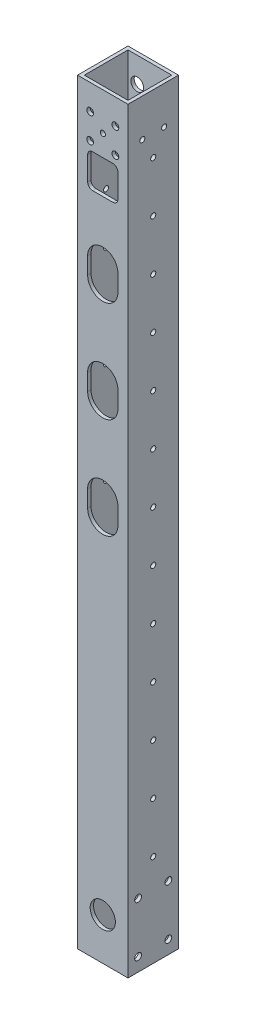
from build123d import *

# Parameters (mm, degrees)
SKETCH_2_W               = 30
SKETCH_2_H               = 30
EXTRUDE_1_DEPTH          = 225
SKETCH_4_W               = 26
SKETCH_4_H               = 26
CUT_EXTRUDE_1_DEPTH      = 226
CUT_EXTRUDE_1_DEPTH_BACK = 226
SKETCH_5_R               = 2.025
CUT_EXTRUDE_2_DEPTH      = 1
CUT_EXTRUDE_2_DEPTH_BACK = 31
SKETCH_7_R               = 1.525
CUT_EXTRUDE_3_DEPTH      = 1
CUT_EXTRUDE_3_DEPTH_BACK = 31
SKETCH_8_R               = 1.525
CUT_EXTRUDE_4_DEPTH      = 31
PATTERN_LINEAR_1_COUNT   = 13
PATTERN_LINEAR_1_PITCH   = 30
SKETCH_9_R               = 3.8
CUT_EXTRUDE_5_DEPTH      = 5
CUT_EXTRUDE_6_DEPTH      = 5
PATTERN_LINEAR_2_COUNT   = 7
PATTERN_LINEAR_2_PITCH   = 57
SKETCH_11_R              = 2.025
CUT_EXTRUDE_7_DEPTH      = 1
CUT_EXTRUDE_7_DEPTH_BACK = 31
CUT_EXTRUDE_8_DEPTH      = 10
SKETCH_14_R              = 1.525
CUT_EXTRUDE_9_DEPTH      = 1
CUT_EXTRUDE_9_DEPTH_BACK = 31
SKETCH_15_R              = 7.5
CUT_EXTRUDE_10_DEPTH     = 2


with BuildPart() as part:
    # 草图2 → 凸台-拉伸1 (new body, symmetric)
    with BuildSketch(Plane(origin=(0, 0, 0), x_dir=(1, 0, 0), z_dir=(0, 1, 0))):
        Rectangle(SKETCH_2_W, SKETCH_2_H)
    extrude(amount=EXTRUDE_1_DEPTH, both=True)

    # 草图4 → 切除-拉伸1 (cut, two sides)
    with BuildSketch(Plane(origin=(0, 0, 0), x_dir=(1, 0, 0), z_dir=(0, 1, 0))) as cut_extrude_1_sk:
        Rectangle(SKETCH_4_W, SKETCH_4_H)
    extrude(amount=CUT_EXTRUDE_1_DEPTH, mode=Mode.SUBTRACT)
    extrude(cut_extrude_1_sk.sketch, amount=-CUT_EXTRUDE_1_DEPTH_BACK, mode=Mode.SUBTRACT)

    # 草图5 → 切除-拉伸2 (cut, two sides)
    with BuildSketch(Plane(origin=(0, 0, -15), x_dir=(-1, 0, 0), z_dir=(0, 0, -1))) as cut_extrude_2_sk:
        with Locations((-7.5, 210)):
            Circle(SKETCH_5_R)
        with Locations((7.5, 210)):
            Circle(SKETCH_5_R)
        with Locations((-7.5, 195)):
            Circle(SKETCH_5_R)
        with Locations((7.5, 195)):
            Circle(SKETCH_5_R)
    extrude(amount=CUT_EXTRUDE_2_DEPTH, mode=Mode.SUBTRACT)
    extrude(cut_extrude_2_sk.sketch, amount=-CUT_EXTRUDE_2_DEPTH_BACK, mode=Mode.SUBTRACT)

    # 草图7 → 切除-拉伸3 (cut, two sides)
    with BuildSketch(Plane(origin=(15, 0, 0), x_dir=(0, 0, -1), z_dir=(1, 0, 0))) as cut_extrude_3_sk:
        with Locations((-6.5, 202.499999999)):
            Circle(SKETCH_7_R)
        with Locations((6.5, 202.499999999)):
            Circle(SKETCH_7_R)
    extrude(amount=CUT_EXTRUDE_3_DEPTH, mode=Mode.SUBTRACT)
    extrude(cut_extrude_3_sk.sketch, amount=-CUT_EXTRUDE_3_DEPTH_BACK, mode=Mode.SUBTRACT)

    # 草图8 → 切除-拉伸4 (cut, through all)
    with BuildSketch(Plane.ZY.offset(15)):
        with Locations((0, -170.000000001)):
            Circle(SKETCH_8_R)
    cut_extrude_4 = extrude(amount=-CUT_EXTRUDE_4_DEPTH, mode=Mode.SUBTRACT)

    # 阵列(线性)1: 切除-拉伸4 ×13
    with Locations(*[(0, i * PATTERN_LINEAR_1_PITCH, 0) for i in range(1, PATTERN_LINEAR_1_COUNT)]):
        add(cut_extrude_4, mode=Mode.SUBTRACT)

    # 草图9 → 切除-拉伸5 (cut)
    with BuildSketch(Plane(origin=(0, 0, -15), x_dir=(-1, 0, 0), z_dir=(0, 0, -1))):
        with Locations((-7.5, 210)):
            Circle(SKETCH_9_R)
        with Locations((7.5, 210)):
            Circle(SKETCH_9_R)
        with Locations((7.5, 195)):
            Circle(SKETCH_9_R)
        with Locations((-7.5, 195)):
            Circle(SKETCH_9_R)
    extrude(amount=-CUT_EXTRUDE_5_DEPTH, mode=Mode.SUBTRACT)

    # 草图10 → 切除-拉伸6 (cut)
    with BuildSketch(Plane(origin=(0, 0, -15), x_dir=(-1, 0, 0), z_dir=(0, 0, -1))):
        with BuildLine():
            Line((-9, -196.5), (-9, -165.5))
            ThreePointArc((-9, -165.5), (0, -156.5), (9, -165.5))
            Line((9, -165.5), (9, -196.5))
            ThreePointArc((9, -196.5), (0, -205.5), (-9, -196.5))
        make_face()
    cut_extrude_6 = extrude(amount=-CUT_EXTRUDE_6_DEPTH, mode=Mode.SUBTRACT)

    # 阵列(线性)2: 切除-拉伸6 ×7
    with Locations(*[(0, i * PATTERN_LINEAR_2_PITCH, 0) for i in range(1, PATTERN_LINEAR_2_COUNT)]):
        add(cut_extrude_6, mode=Mode.SUBTRACT)

    # 草图11 → 切除-拉伸7 (cut, two sides)
    with BuildSketch(Plane.ZY.offset(15)) as cut_extrude_7_sk:
        with Locations((-9, -187)):
            Circle(SKETCH_11_R)
        with Locations((9, -187)):
            Circle(SKETCH_11_R)
        with Locations((-9, -217)):
            Circle(SKETCH_11_R)
        with Locations((9, -217)):
            Circle(SKETCH_11_R)
    extrude(amount=CUT_EXTRUDE_7_DEPTH, mode=Mode.SUBTRACT)
    extrude(cut_extrude_7_sk.sketch, amount=-CUT_EXTRUDE_7_DEPTH_BACK, mode=Mode.SUBTRACT)

    # 草图13 → 切除-拉伸8 (cut)
    with BuildSketch(Plane.XY.offset(15)):
        with BuildLine():
            Line((-6, 190), (6, 190))
            ThreePointArc((6, 190), (8.121320344, 189.121320344), (9, 187))
            Line((9, 187), (9, 173))
            ThreePointArc((9, 173), (8.121320344, 170.878679656), (6, 170))
            Line((6, 170), (-6, 170))
            ThreePointArc((-6, 170), (-8.121320344, 170.878679656), (-9, 173))
            Line((-9, 173), (-9, 187))
            ThreePointArc((-9, 187), (-8.121320344, 189.121320344), (-6, 190))
        make_face()
        with BuildLine():
            Line((9, 135), (9, 125))
            ThreePointArc((9, 125), (0, 116), (-9, 125))
            Line((-9, 125), (-9, 135))
            ThreePointArc((-9, 135), (0, 144), (9, 135))
        make_face()
        with BuildLine():
            Line((-9, 65), (-9, 75))
            ThreePointArc((-9, 75), (0, 84), (9, 75))
            Line((9, 75), (9, 65))
            ThreePointArc((9, 65), (0, 56), (-9, 65))
        make_face()
        with BuildLine():
            Line((-9, 5), (-9, 15))
            ThreePointArc((-9, 15), (0, 24), (9, 15))
            Line((9, 15), (9, 5))
            ThreePointArc((9, 5), (0, -4), (-9, 5))
        make_face()
    extrude(amount=-CUT_EXTRUDE_8_DEPTH, mode=Mode.SUBTRACT)

    # 草图14 → 切除-拉伸9 (cut, two sides)
    with BuildSketch(Plane(origin=(0, 0, -15), x_dir=(-1, 0, 0), z_dir=(0, 0, -1))) as cut_extrude_9_sk:
        with Locations((-0.05, 202.5)):
            Circle(SKETCH_14_R)
    extrude(amount=CUT_EXTRUDE_9_DEPTH, mode=Mode.SUBTRACT)
    extrude(cut_extrude_9_sk.sketch, amount=-CUT_EXTRUDE_9_DEPTH_BACK, mode=Mode.SUBTRACT)

    # 草图15 → 切除-拉伸10 (cut)
    with BuildSketch(Plane(origin=(0, 0, 13), x_dir=(-1, 0, 0), z_dir=(0, 0, -1))):
        with Locations((0, -200)):
            Circle(SKETCH_15_R)
    extrude(amount=-CUT_EXTRUDE_10_DEPTH, mode=Mode.SUBTRACT)


solid = part.part
